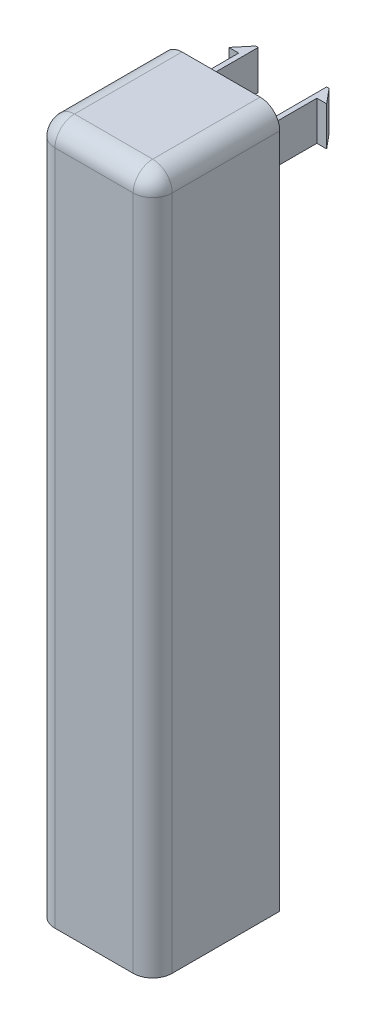
from build123d import *

# Parameters (mm, degrees)
BOSS_EXTRUDE1_DEPTH    = 11
SKETCH2_W              = 2
SKETCH2_H              = 6
BOSS_EXTRUDE2_DEPTH    = 2
SKETCH1_3_W            = 2
SKETCH1_3_H            = 100
BOSS_EXTRUDE3_DEPTH    = 11
SKETCH3_W              = 12
SKETCH3_H              = 100
BOSS_EXTRUDE4_DEPTH    = 2
SKETCH10_W             = 12
SKETCH10_H             = 28.85
CUT_EXTRUDE3_DEPTH     = 14
SKETCH11_W             = 12
SKETCH11_H             = 13
BOSS_EXTRUDE8_DEPTH    = 2
SKETCH12_W             = 8
SKETCH12_H             = 11
CUT_EXTRUDE4_DEPTH     = 2
SKETCH17_W             = 13
SKETCH17_H             = 16.3
CUT_EXTRUDE7_DEPTH     = 26.8
SKETCH18_W             = 11
SKETCH18_H             = 6
BOSS_EXTRUDE11_DEPTH   = 2
SKETCH19_W             = 8
SKETCH19_H             = 11
BOSS_EXTRUDE12_DEPTH   = 2
FILLET8_R              = 2
SKETCH20_W             = 0.5
SKETCH20_H             = 4
BOSS_EXTRUDE13_DEPTH   = 5.8
BOSS_EXTRUDE13_2_DEPTH = 5.8
BOSS_EXTRUDE14_DEPTH   = 4


with BuildPart() as part:
    # Sketch1 → Boss-Extrude1 (new body)
    with BuildSketch(Plane.XY):
        Polygon((24.8, 14.3), (-2, 14.3), (-2, -2), (24.8, -2), (24.8, 3.15), (22.8, 3.15), (22.8, 0), (0, 0), (0, 12.3), (22.8, 12.3), (22.8, 9.15), (24.8, 9.15), align=None)
    extrude(amount=BOSS_EXTRUDE1_DEPTH)

    # Sketch2 → Boss-Extrude2 (add)
    with BuildSketch(Plane.XY.offset(11)):
        Polygon((22.8, 9.15), (22.8, 3.15), (22.8, 0), (0, 0), (0, 12.3), (22.8, 12.3), align=None)
        Polygon((24.8, -2), (24.8, 3.15), (22.8, 3.15), (22.8, 0), (0, 0), (0, 12.3), (22.8, 12.3), (22.8, 9.15), (24.8, 9.15), (24.8, 14.3), (-2, 14.3), (-2, -2), align=None)
        with Locations((23.8, 6.15)):
            Rectangle(SKETCH2_W, SKETCH2_H)
    extrude(amount=BOSS_EXTRUDE2_DEPTH)

    # Sketch1_3 → Boss-Extrude3 (add)
    with BuildSketch(Plane.XY):
        Polygon((24.8, 3.15), (24.8, -2), (24.8, -43.85), (26.8, -43.85), (26.8, 3.15), align=None)
        Polygon((24.8, 56.15), (24.8, 14.3), (24.8, 9.15), (26.8, 9.15), (26.8, 56.15), align=None)
        with Locations((35.8, 6.15)):
            Rectangle(SKETCH1_3_W, SKETCH1_3_H)
    extrude(amount=BOSS_EXTRUDE3_DEPTH)

    # Sketch3 → Boss-Extrude4 (add)
    with BuildSketch(Plane.XY.offset(11)):
        with Locations((30.8, 6.15)):
            Rectangle(SKETCH3_W, SKETCH3_H)
    extrude(amount=BOSS_EXTRUDE4_DEPTH)

    # Sketch10 → Cut-Extrude3 (cut, through all)
    with BuildSketch(Plane.XY.offset(13)):
        with Locations((30.8, 41.725)):
            Rectangle(SKETCH10_W, SKETCH10_H)
    extrude(amount=-CUT_EXTRUDE3_DEPTH, mode=Mode.SUBTRACT)

    # Sketch11 → Boss-Extrude8 (add)
    with BuildSketch(Plane(origin=(0, 27.3, 0), x_dir=(1, 0, 0), z_dir=(0, 1, 0))):
        with Locations((30.8, -6.5)):
            Rectangle(SKETCH11_W, SKETCH11_H)
    extrude(amount=-BOSS_EXTRUDE8_DEPTH)

    # Sketch12 → Cut-Extrude4 (cut)
    with BuildSketch(Plane.XY.offset(13)):
        with Locations((30.8, 19.8)):
            Rectangle(SKETCH12_W, SKETCH12_H)
    extrude(amount=-CUT_EXTRUDE4_DEPTH, mode=Mode.SUBTRACT)

    # Sketch17 → Cut-Extrude7 (cut)
    with BuildSketch(Plane.ZY.offset(2)):
        with Locations((6.5, 6.15)):
            Rectangle(SKETCH17_W, SKETCH17_H)
    extrude(amount=-CUT_EXTRUDE7_DEPTH, mode=Mode.SUBTRACT)

    # Sketch18 → Boss-Extrude11 (add)
    with BuildSketch(Plane.ZY.offset(-24.8)):
        with Locations((5.5, 6.15)):
            Rectangle(SKETCH18_W, SKETCH18_H)
    extrude(amount=-BOSS_EXTRUDE11_DEPTH)

    # Sketch19 → Boss-Extrude12 (add)
    with BuildSketch(Plane.XY.offset(13)):
        with Locations((30.8, 19.8)):
            Rectangle(SKETCH19_W, SKETCH19_H)
    extrude(amount=-BOSS_EXTRUDE12_DEPTH)

    # Fillet8
    fillet8_edges = [part.edges().sort_by_distance(p)[0] for p in [
        (36.8, 27.3, 6.5),
        (24.8, 27.3, 6.5),
        (30.8, 27.3, 13),
        (24.8, -8.275, 13),
        (36.8, -8.275, 13),
    ]]
    fillet(fillet8_edges, radius=FILLET8_R)



with BuildPart() as body_2:
    # Sketch20 → Boss-Extrude13 (new body)
    with BuildSketch(Plane(origin=(0, 0, 0), x_dir=(-1, 0, 0), z_dir=(0, 0, -1))):
        with Locations((-34.55, 22.3)):
            Rectangle(SKETCH20_W, SKETCH20_H)
    extrude(amount=BOSS_EXTRUDE13_DEPTH)


with BuildPart() as body_3:
    # Sketch20 → Boss-Extrude13 2 (new body)
    with BuildSketch(Plane(origin=(0, 0, 0), x_dir=(-1, 0, 0), z_dir=(0, 0, -1))):
        with Locations((-27.05, 22.3)):
            Rectangle(SKETCH20_W, SKETCH20_H)
    extrude(amount=BOSS_EXTRUDE13_2_DEPTH)


with BuildPart() as part_1:
    add(part.part)

    add(body_2.part)  # Boss-Extrude14 merges body 2

    add(body_3.part)  # Boss-Extrude14 merges body 3
    # Sketch21 → Boss-Extrude14 (add)
    with BuildSketch(Plane.XZ.offset(-20.3)):
        Polygon((27.3, 0.5), (26.8, 1), (26.8, 0.5), (26.8, 0), (27.3, 0), align=None)
        Polygon((26.8, -5.8), (25.8, -5.8), (27.05, -7.3), (27.3, -7.3), (27.3, -5.8), align=None)
        Polygon((34.3, -5.8), (34.8, -5.8), (35.8, -5.8), (34.55, -7.3), (34.3, -7.3), align=None)
        Polygon((34.8, 0), (34.3, 0), (34.3, 0.5), (34.8, 1), (34.8, 0.5), align=None)
    extrude(amount=-BOSS_EXTRUDE14_DEPTH)


solid = part_1.part
